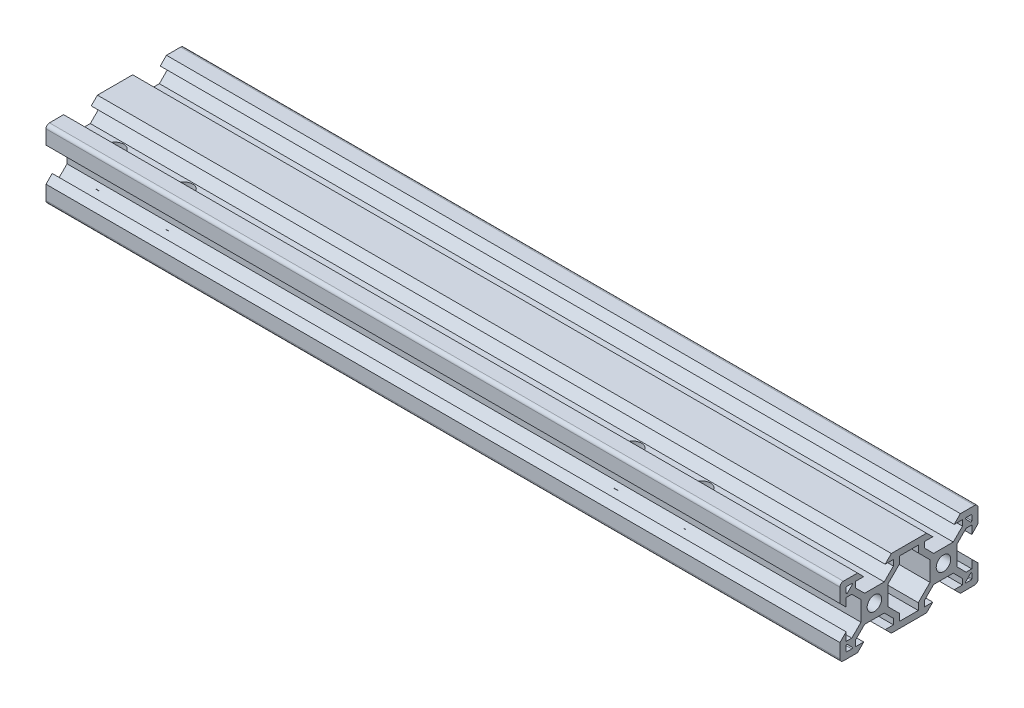
from build123d import *

# Parameters (mm, degrees)
SKETCH5_R           = 2.1
BOSS_EXTRUDE1_DEPTH = 115
CUT_EXTRUDE1_REACH  = 22
SKETCH7_R           = 2.5
SKETCH8_R           = 5
CUT_EXTRUDE2_DEPTH  = 6.1


with BuildPart() as part:
    # Sketch5 → Boss-Extrude1 (new body, symmetric)
    with BuildSketch(Plane(origin=(0, 0, 0), x_dir=(0, 0, -1), z_dir=(1, 0, 0))):
        with BuildLine():
            Line((-19.998019485, 4.9), (-18.198019485, 3.1))
            Line((-18.198019485, 3.1), (-18.198019485, 5.499339828))
            Line((-18.198019485, 5.499339828), (-16.558019485, 5.499339828))
            Line((-16.558019485, 5.499339828), (-13.9, 2.841320344))
            Line((-13.9, 2.841320344), (-13.9, -2.838679656))
            Line((-13.9, -2.838679656), (-16.558019485, -5.496699141))
            Line((-16.558019485, -5.496699141), (-18.198019485, -5.496699141))
            Line((-18.198019485, -5.496699141), (-18.198019485, -3.1))
            Line((-18.198019485, -3.1), (-19.998019485, -4.9))
            Line((-19.998019485, -4.9), (-19.998019485, -9))
            ThreePointArc((-19.998019485, -9), (-19.705126266, -9.707106781), (-18.998019485, -10))
            Line((-18.998019485, -10), (-14.9, -10))
            Line((-14.9, -10), (-13.1, -8.2))
            Line((-13.1, -8.2), (-15.5, -8.2))
            Line((-15.5, -8.2), (-15.5, -6.56))
            Line((-15.5, -6.56), (-12.84, -3.9))
            Line((-12.84, -3.9), (-7.16, -3.9))
            Line((-7.16, -3.9), (-4.5, -6.56))
            Line((-4.5, -6.56), (-4.5, -8.2))
            Line((-4.5, -8.2), (-6.9, -8.2))
            Line((-6.9, -8.2), (-5.1, -10))
            Line((-5.1, -10), (5.1, -10))
            Line((5.1, -10), (6.9, -8.2))
            Line((6.9, -8.2), (4.496038969, -8.2))
            Line((4.496038969, -8.2), (4.496038969, -6.56))
            Line((4.496038969, -6.56), (7.156038969, -3.9))
            Line((7.156038969, -3.9), (12.836038969, -3.9))
            Line((12.836038969, -3.9), (15.496038969, -6.56))
            Line((15.496038969, -6.56), (15.496038969, -8.2))
            Line((15.496038969, -8.2), (13.1, -8.2))
            Line((13.1, -8.2), (14.9, -10))
            Line((14.9, -10), (19.001980515, -10))
            ThreePointArc((19.001980515, -10), (19.709087297, -9.707106781), (20.001980515, -9))
            Line((20.001980515, -9), (20.001980515, -4.9))
            Line((20.001980515, -4.9), (18.201980515, -3.1))
            Line((18.201980515, -3.1), (18.201980515, -5.504621202))
            Line((18.201980515, -5.504621202), (16.561980515, -5.504621202))
            Line((16.561980515, -5.504621202), (13.9, -2.842640687))
            Line((13.9, -2.842640687), (13.9, 2.837359313))
            Line((13.9, 2.837359313), (16.561980515, 5.499339828))
            Line((16.561980515, 5.499339828), (18.201980515, 5.499339828))
            Line((18.201980515, 5.499339828), (18.201980515, 3.1))
            Line((18.201980515, 3.1), (20.001980515, 4.9))
            Line((20.001980515, 4.9), (20.001980515, 9))
            ThreePointArc((20.001980515, 9), (19.709087297, 9.707106781), (19.001980515, 10))
            Line((19.001980515, 10), (14.9, 10))
            Line((14.9, 10), (13.1, 8.2))
            Line((13.1, 8.2), (15.501320344, 8.2))
            Line((15.501320344, 8.2), (15.501320344, 6.56))
            Line((15.501320344, 6.56), (12.841320344, 3.9))
            Line((12.841320344, 3.9), (7.161320344, 3.9))
            Line((7.161320344, 3.9), (4.501320344, 6.56))
            Line((4.501320344, 6.56), (4.501320344, 8.2))
            Line((4.501320344, 8.2), (6.9, 8.2))
            Line((6.9, 8.2), (5.1, 10))
            Line((5.1, 10), (-5.1, 10))
            Line((-5.1, 10), (-6.9, 8.2))
            Line((-6.9, 8.2), (-4.501320344, 8.2))
            Line((-4.501320344, 8.2), (-4.501320344, 6.56))
            Line((-4.501320344, 6.56), (-7.161320344, 3.9))
            Line((-7.161320344, 3.9), (-12.841320344, 3.9))
            Line((-12.841320344, 3.9), (-15.501320344, 6.56))
            Line((-15.501320344, 6.56), (-15.501320344, 8.2))
            Line((-15.501320344, 8.2), (-13.1, 8.2))
            Line((-13.1, 8.2), (-14.9, 10))
            Line((-14.9, 10), (-18.998019485, 10))
            ThreePointArc((-18.998019485, 10), (-19.705126266, 9.707106781), (-19.998019485, 9))
            Line((-19.998019485, 9), (-19.998019485, 4.9))
        make_face()
        with Locations((-10, 0)):
            Circle(SKETCH5_R, mode=Mode.SUBTRACT)
        with Locations((10, 0)):
            Circle(SKETCH5_R, mode=Mode.SUBTRACT)
        Polygon((6.1, -2.84), (6.1, 2.84), (2.7, 6.24), (2.7, 8.2), (-2.7, 8.2), (-2.7, 6.24), (-6.1, 2.84), (-6.1, -2.84), (-2.7, -6.24), (-2.7, -8.2), (2.7, -8.2), (2.7, -6.24), align=None, mode=Mode.SUBTRACT)
        with BuildLine():
            Line((16.571320344, 8.2), (18.001980515, 8.2))
            ThreePointArc((18.001980515, 8.2), (18.143401872, 8.141421356), (18.201980515, 8))
            Line((18.201980515, 8), (18.201980515, 6.569339828))
            ThreePointArc((18.201980515, 6.569339828), (18.078517202, 6.384563922), (17.860559159, 6.427918472))
            Line((17.860559159, 6.427918472), (16.429898987, 7.858578644))
            ThreePointArc((16.429898987, 7.858578644), (16.386544437, 8.076536686), (16.571320344, 8.2))
        make_face(mode=Mode.SUBTRACT)
        with BuildLine():
            Line((16.571320344, -8.2), (18.001980515, -8.2))
            ThreePointArc((18.001980515, -8.2), (18.143401872, -8.141421356), (18.201980515, -8))
            Line((18.201980515, -8), (18.201980515, -6.569339828))
            ThreePointArc((18.201980515, -6.569339828), (18.078517202, -6.384563922), (17.860559159, -6.427918472))
            Line((17.860559159, -6.427918472), (16.429898987, -7.858578644))
            ThreePointArc((16.429898987, -7.858578644), (16.386544437, -8.076536686), (16.571320344, -8.2))
        make_face(mode=Mode.SUBTRACT)
        with BuildLine():
            Line((-17.860559159, 6.427918472), (-16.429898987, 7.858578644))
            ThreePointArc((-16.429898987, 7.858578644), (-16.386544437, 8.076536686), (-16.571320344, 8.2))
            Line((-16.571320344, 8.2), (-18.001980515, 8.2))
            ThreePointArc((-18.001980515, 8.2), (-18.143401872, 8.141421356), (-18.201980515, 8))
            Line((-18.201980515, 8), (-18.201980515, 6.569339828))
            ThreePointArc((-18.201980515, 6.569339828), (-18.078517202, 6.384563922), (-17.860559159, 6.427918472))
        make_face(mode=Mode.SUBTRACT)
        with BuildLine():
            Line((-16.571320344, -8.2), (-18.001980515, -8.2))
            ThreePointArc((-18.001980515, -8.2), (-18.143401872, -8.141421356), (-18.201980515, -8))
            Line((-18.201980515, -8), (-18.201980515, -6.569339828))
            ThreePointArc((-18.201980515, -6.569339828), (-18.078517202, -6.384563922), (-17.860559159, -6.427918472))
            Line((-17.860559159, -6.427918472), (-16.429898987, -7.858578644))
            ThreePointArc((-16.429898987, -7.858578644), (-16.386544437, -8.076536686), (-16.571320344, -8.2))
        make_face(mode=Mode.SUBTRACT)
    extrude(amount=BOSS_EXTRUDE1_DEPTH, both=True)

    # Sketch7 → Cut-Extrude1 (cut, up to next)
    with BuildSketch(Plane.XZ.offset(10), mode=Mode.PRIVATE) as cut_extrude1_sk1:
        with Locations((-105, 10)):
            Circle(SKETCH7_R)
    cut_extrude1_tool1 = extrude(cut_extrude1_sk1.sketch, amount=-CUT_EXTRUDE1_REACH, mode=Mode.PRIVATE) & part.part
    add(cut_extrude1_tool1.solids().sort_by_distance((-105, -10, 10))[0], mode=Mode.SUBTRACT)
    # Sketch7 → Cut-Extrude1 (cut, up to next)
    with BuildSketch(Plane.XZ.offset(10), mode=Mode.PRIVATE) as cut_extrude1_sk2:
        with Locations((-85, 10)):
            Circle(SKETCH7_R)
    cut_extrude1_tool2 = extrude(cut_extrude1_sk2.sketch, amount=-CUT_EXTRUDE1_REACH, mode=Mode.PRIVATE) & part.part
    add(cut_extrude1_tool2.solids().sort_by_distance((-85, -10, 10))[0], mode=Mode.SUBTRACT)
    # Sketch7 → Cut-Extrude1 (cut, up to next)
    with BuildSketch(Plane.XZ.offset(10), mode=Mode.PRIVATE) as cut_extrude1_sk3:
        with Locations((65, 10)):
            Circle(SKETCH7_R)
    cut_extrude1_tool3 = extrude(cut_extrude1_sk3.sketch, amount=-CUT_EXTRUDE1_REACH, mode=Mode.PRIVATE) & part.part
    add(cut_extrude1_tool3.solids().sort_by_distance((65, -10, 10))[0], mode=Mode.SUBTRACT)
    # Sketch7 → Cut-Extrude1 (cut, up to next)
    with BuildSketch(Plane.XZ.offset(10), mode=Mode.PRIVATE) as cut_extrude1_sk4:
        with Locations((45, 10)):
            Circle(SKETCH7_R)
    cut_extrude1_tool4 = extrude(cut_extrude1_sk4.sketch, amount=-CUT_EXTRUDE1_REACH, mode=Mode.PRIVATE) & part.part
    add(cut_extrude1_tool4.solids().sort_by_distance((45, -10, 10))[0], mode=Mode.SUBTRACT)

    # Sketch8 → Cut-Extrude2 (cut)
    with BuildSketch(Plane.XZ.offset(10)):
        with Locations((-105, 10)):
            Circle(SKETCH8_R)
        with Locations((-85, 10)):
            Circle(SKETCH8_R)
        with Locations((45, 10)):
            Circle(SKETCH8_R)
        with Locations((65, 10)):
            Circle(SKETCH8_R)
    extrude(amount=-CUT_EXTRUDE2_DEPTH, mode=Mode.SUBTRACT)


solid = part.part
